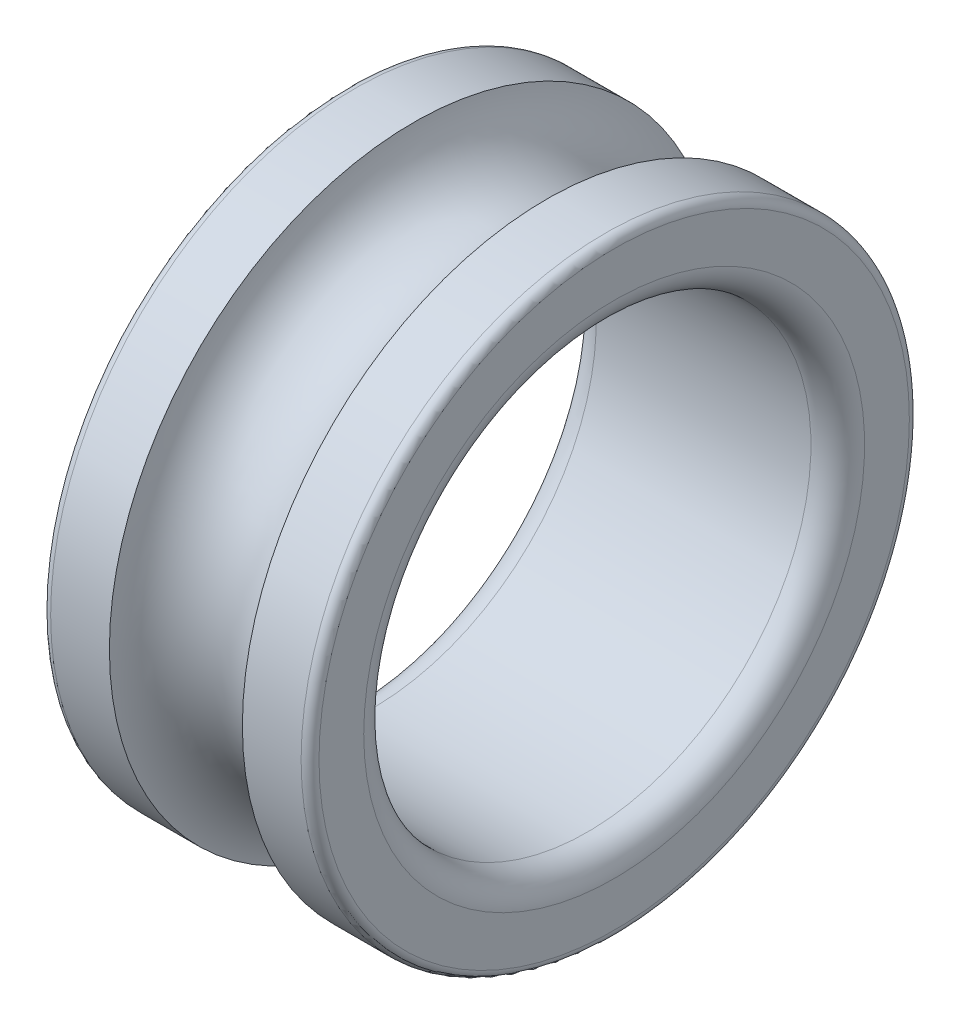
from build123d import *


with BuildPart() as part:
    # Sketch1 → Revolve1 (revolve)
    with BuildSketch(Plane(origin=(0, 0, 0), x_dir=(-1, 0, 0), z_dir=(0, 0, -1))):
        with BuildLine():
            Line((-2.35, 3.4), (-3.006696563, 3.4))
            ThreePointArc((-3.006696563, 3.4), (-3.75, 2.75), (-4.493303437, 3.4))
            Line((-4.493303437, 3.4), (-5.15, 3.4))
            ThreePointArc((-5.15, 3.4), (-5.220710678, 3.370710678), (-5.25, 3.3))
            Line((-5.25, 3.3), (-5.25, 2.8))
            ThreePointArc((-5.25, 2.8), (-5.162132034, 2.587867966), (-4.95, 2.5))
            Line((-4.95, 2.5), (-2.55, 2.5))
            ThreePointArc((-2.55, 2.5), (-2.337867966, 2.587867966), (-2.25, 2.8))
            Line((-2.25, 2.8), (-2.25, 3.3))
            ThreePointArc((-2.25, 3.3), (-2.279289322, 3.370710678), (-2.35, 3.4))
        make_face()
    revolve(axis=Axis((7.001253994, 0, 0), (-1, 0, 0)))


solid = part.part
